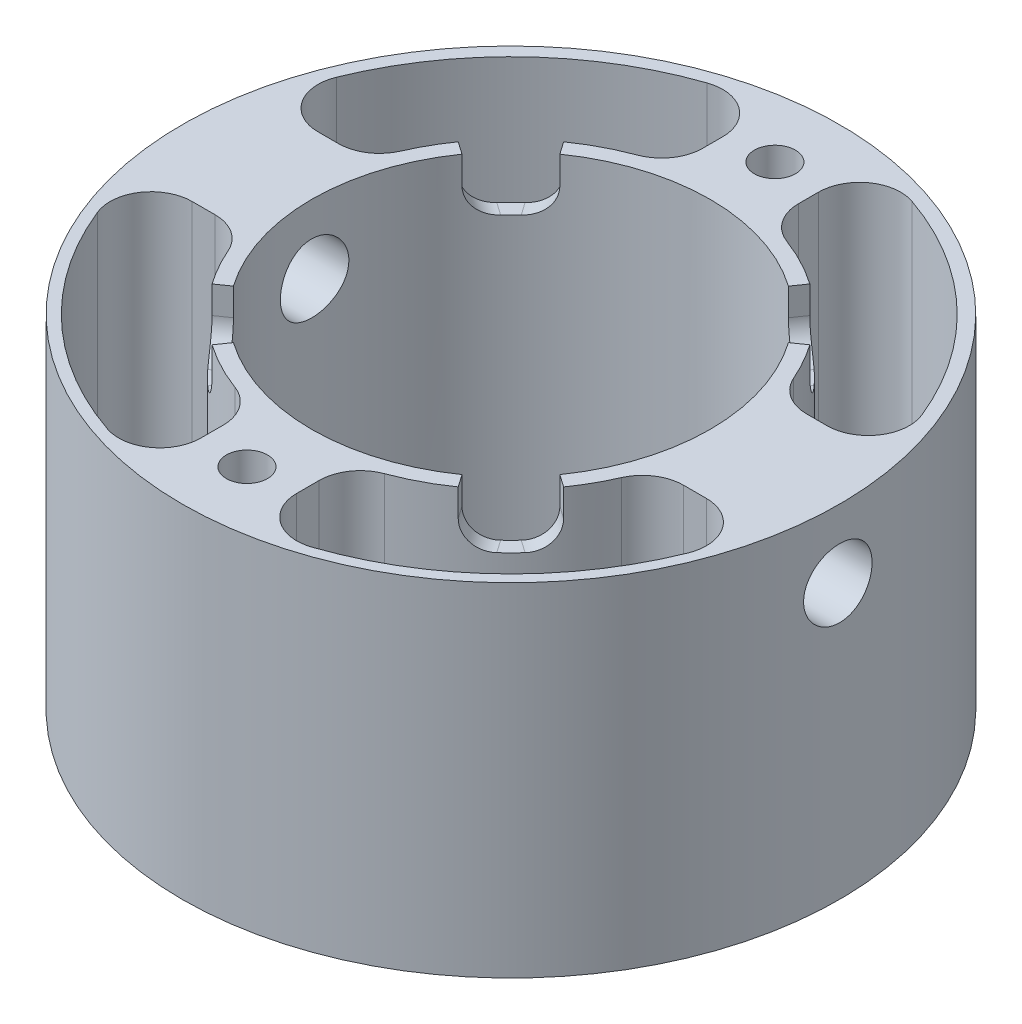
from build123d import *

# Parameters (mm, degrees)
SKETCH3_R                = 24
SKETCH3_R_2              = 14.55
BOSS_EXTRUDE1_DEPTH      = 10
BOSS_EXTRUDE1_DEPTH_BACK = 15
CUT_EXTRUDE2_START       = 50
SKETCH4_R                = 2.5
CUT_EXTRUDE2_DEPTH       = 100
SKETCH5_R                = 1.5
CUT_EXTRUDE3_DEPTH       = 100
CUT_EXTRUDE6_DEPTH       = 26
CUT_EXTRUDE7_DEPTH       = 26
CUT_EXTRUDE8_DEPTH       = 26
CUT_EXTRUDE9_DEPTH       = 26
FILLET5_R                = 3
CUT_EXTRUDE12_DEPTH      = 4
FILLET10_R               = 2
SKETCH20_R               = 2.5
CUT_EXTRUDE13_DEPTH      = 15


with BuildPart() as part:
    # Sketch3 → Boss-Extrude1 (new body, two sides)
    with BuildSketch(Plane(origin=(0, 0, 0), x_dir=(1, 0, 0), z_dir=(0, 1, 0))) as boss_extrude1_sk:
        Circle(SKETCH3_R)
        Circle(SKETCH3_R_2, mode=Mode.SUBTRACT)
    extrude(amount=BOSS_EXTRUDE1_DEPTH)
    extrude(boss_extrude1_sk.sketch, amount=-BOSS_EXTRUDE1_DEPTH_BACK)

    # Sketch4 → Cut-Extrude2 (cut)
    with BuildSketch(Plane(origin=(0, 0, 0), x_dir=(0, 0, -1), z_dir=(1, 0, 0)).offset(CUT_EXTRUDE2_START)):
        with Locations((0, 5)):
            Circle(SKETCH4_R)
    extrude(amount=-CUT_EXTRUDE2_DEPTH, mode=Mode.SUBTRACT)

    # Sketch5 → Cut-Extrude3 (cut)
    with BuildSketch(Plane(origin=(0, 10, 0), x_dir=(1, 0, 0), z_dir=(0, 1, 0))):
        with Locations((0, 19.275)):
            Circle(SKETCH5_R)
        with Locations((0, -19.275)):
            Circle(SKETCH5_R)
    extrude(amount=-CUT_EXTRUDE3_DEPTH, mode=Mode.SUBTRACT)

    # Sketch7 → Cut-Extrude6 (cut)
    with BuildSketch(Plane(origin=(0, 10, 0), x_dir=(1, 0, 0), z_dir=(0, 1, 0))):
        with BuildLine():
            Line((3.5, 15.275), (3.5, 22.775))
            ThreePointArc((3.5, 22.775), (15.930450829, 16.648464235), (22.598686356, 4.5))
            Line((22.598686356, 4.5), (15.010850242, 4.5))
            ThreePointArc((15.010850242, 4.5), (10.709250694, 11.440610761), (3.5, 15.275))
        make_face()
    extrude(amount=-CUT_EXTRUDE6_DEPTH, mode=Mode.SUBTRACT)

    # Sketch9 → Cut-Extrude7 (cut)
    with BuildSketch(Plane(origin=(0, 10, 0), x_dir=(1, 0, 0), z_dir=(0, 1, 0))):
        with BuildLine():
            Line((15.010850242, -4.5), (22.775, -4.5))
            ThreePointArc((22.775, -4.5), (16.052855024, -16.770702746), (3.5, -22.94995915))
            Line((3.5, -22.94995915), (3.5, -15.275))
            ThreePointArc((3.5, -15.275), (10.709250694, -11.440610761), (15.010850242, -4.5))
        make_face()
    extrude(amount=-CUT_EXTRUDE7_DEPTH, mode=Mode.SUBTRACT)

    # Sketch10 → Cut-Extrude8 (cut)
    with BuildSketch(Plane(origin=(0, 10, 0), x_dir=(1, 0, 0), z_dir=(0, 1, 0))):
        with BuildLine():
            Line((-3.5, 15.275), (-3.5, 22.775))
            ThreePointArc((-3.5, 22.775), (-15.930450829, 16.648464235), (-22.598686356, 4.5))
            Line((-22.598686356, 4.5), (-15.010850242, 4.5))
            ThreePointArc((-15.010850242, 4.5), (-10.709250694, 11.440610761), (-3.5, 15.275))
        make_face()
    extrude(amount=-CUT_EXTRUDE8_DEPTH, mode=Mode.SUBTRACT)

    # Sketch11 → Cut-Extrude9 (cut)
    with BuildSketch(Plane(origin=(0, 10, 0), x_dir=(1, 0, 0), z_dir=(0, 1, 0))):
        with BuildLine():
            Line((-15.010850242, -4.5), (-22.775, -4.5))
            ThreePointArc((-22.775, -4.5), (-16.052855024, -16.770702746), (-3.5, -22.94995915))
            Line((-3.5, -22.94995915), (-3.5, -15.275))
            ThreePointArc((-3.5, -15.275), (-10.709250694, -11.440610761), (-15.010850242, -4.5))
        make_face()
    extrude(amount=-CUT_EXTRUDE9_DEPTH, mode=Mode.SUBTRACT)

    # Fillet5
    fillet5_edges = [part.edges().sort_by_distance(p)[0] for p in [
        (-3.5, -2.5, 22.94995915),
        (-22.775, -2.5, 4.5),
        (-15.010850242, -2.5, 4.5),
        (-3.5, -2.5, 15.275),
        (3.5, -2.5, -22.775),
        (22.598686356, -2.5, -4.5),
        (15.010850242, -2.5, -4.5),
        (3.5, -2.5, -15.275),
        (3.5, -2.5, 15.275),
        (15.010850242, -2.5, 4.5),
        (22.775, -2.5, 4.5),
        (3.5, -2.5, 22.94995915),
        (-3.5, -2.5, -15.275),
        (-15.010850242, -2.5, -4.5),
        (-22.598686356, -2.5, -4.5),
        (-3.5, -2.5, -22.775),
    ]]
    fillet(fillet5_edges, radius=FILLET5_R)

    # Sketch19 → Cut-Extrude12 (cut)
    with BuildSketch(Plane(origin=(0, 10, 0), x_dir=(1, 0, 0), z_dir=(0, 1, 0))):
        with BuildLine():
            Line((-12.836811042, 8.988431858), (-11.918662244, 8.345537149))
            ThreePointArc((-11.918662244, 8.345537149), (-10.288403666, 10.288403666), (-8.345537149, 11.918662244))
            Line((-8.345537149, 11.918662244), (-8.988431858, 12.836811042))
            ThreePointArc((-8.988431858, 12.836811042), (-11.080966226, 11.080966226), (-12.836811042, 8.988431858))
        make_face()
        with BuildLine():
            Line((8.988431858, 12.836811042), (8.345537149, 11.918662244))
            ThreePointArc((8.345537149, 11.918662244), (10.288403666, 10.288403666), (11.918662244, 8.345537149))
            Line((11.918662244, 8.345537149), (12.836811042, 8.988431858))
            ThreePointArc((12.836811042, 8.988431858), (11.080966226, 11.080966226), (8.988431858, 12.836811042))
        make_face()
        with BuildLine():
            ThreePointArc((11.918662244, -8.345537149), (10.288403666, -10.288403666), (8.345537149, -11.918662244))
            Line((8.345537149, -11.918662244), (8.988431858, -12.836811042))
            ThreePointArc((8.988431858, -12.836811042), (11.080966226, -11.080966226), (12.836811042, -8.988431858))
            Line((12.836811042, -8.988431858), (11.918662244, -8.345537149))
        make_face()
        with BuildLine():
            Line((-8.988431858, -12.836811042), (-8.345537149, -11.918662244))
            ThreePointArc((-8.345537149, -11.918662244), (-10.288403666, -10.288403666), (-11.918662244, -8.345537149))
            Line((-11.918662244, -8.345537149), (-12.836811042, -8.988431858))
            ThreePointArc((-12.836811042, -8.988431858), (-11.080966226, -11.080966226), (-8.988431858, -12.836811042))
        make_face()
    extrude(amount=-CUT_EXTRUDE12_DEPTH, mode=Mode.SUBTRACT)

    # Fillet10
    fillet10_edges = [part.edges().sort_by_distance(p)[0] for p in [
        (-12.377736643, 6, 8.666984504),
        (-8.666984504, 6, 12.377736643),
        (8.666984504, 6, 12.377736643),
        (12.377736643, 6, 8.666984504),
        (12.377736643, 6, -8.666984504),
        (8.666984504, 6, -12.377736643),
        (-8.666984504, 6, -12.377736643),
        (-12.377736643, 6, -8.666984504),
    ]]
    fillet(fillet10_edges, radius=FILLET10_R)

    # Sketch20 → Cut-Extrude13 (cut)
    with BuildSketch(Plane.XZ.offset(15)):
        with Locations((-19.275, 0)):
            Circle(SKETCH20_R)
        with Locations((19.275, 0)):
            Circle(SKETCH20_R)
    extrude(amount=-CUT_EXTRUDE13_DEPTH, mode=Mode.SUBTRACT)


solid = part.part
